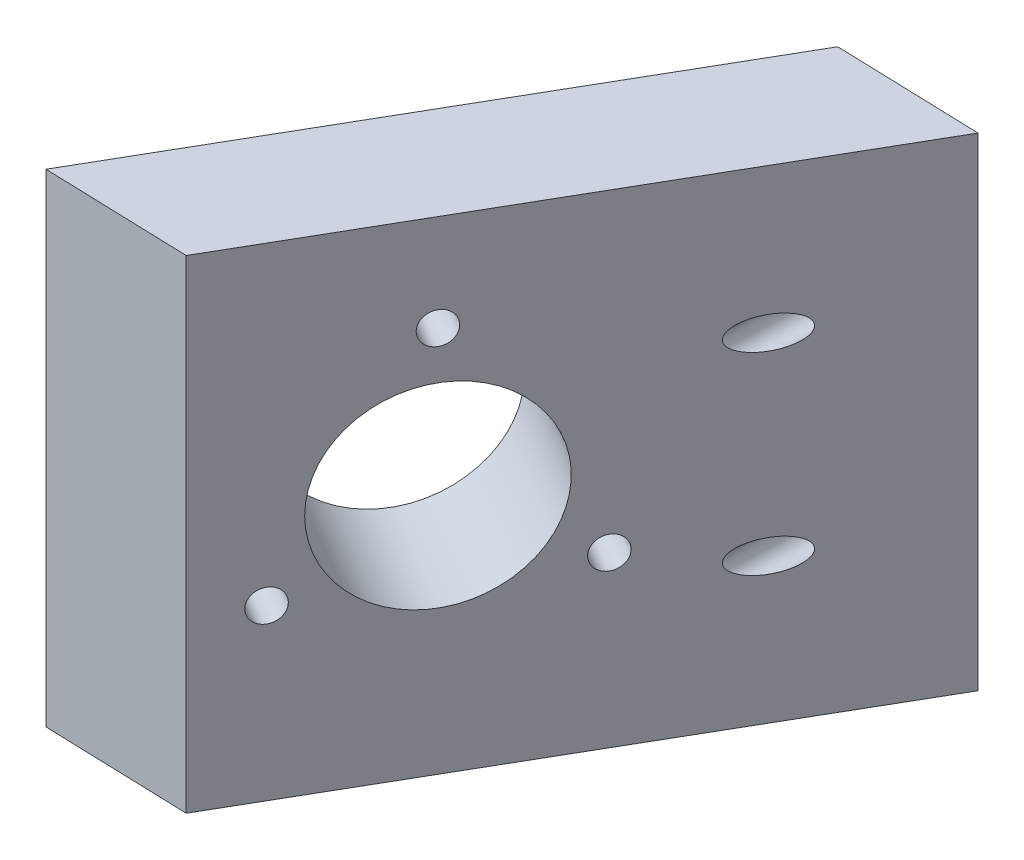
from build123d import *

# Parameters (mm, degrees)
EXTRUDE_1_DEPTH        = 50
HOLE_WIZARD_M4_1_D     = 3.3
HOLE_WIZARD_M4_1_DEPTH = 10.1
HOLE_WIZARD_M4_1_TIP   = 0.991420021
SKETCH_2_R             = 10.1
CUT_EXTRUDE_1_DEPTH    = 50
HOLE_WIZARD_M4_2_D     = 3.3


with BuildPart() as part:
    # 草图1 → 凸台-拉伸1 (new body)
    with BuildSketch(Plane(origin=(0, 0, 0), x_dir=(1, 0, 0), z_dir=(0, 1, 0))):
        Polygon((-12.088519272, -36.909676467), (17.911480728, 15.05184776), (32.903920346, 14.575660494), (2.903920346, -37.385863733), align=None)
    extrude(amount=EXTRUDE_1_DEPTH)

    # M4 螺纹孔1
    with Locations(Plane(origin=(10.045844782, 0, 25.015687746), x_dir=(-0.5, 0, 0.866025404), z_dir=(0.866025404, 0, 0.5))):
        with Locations((-17.783614548, -17.5), (-4.793233491, -40), (8.197147566, -17.5)):
            Hole(HOLE_WIZARD_M4_1_D / 2, depth=HOLE_WIZARD_M4_1_DEPTH)
            with Locations((0, 0, -(HOLE_WIZARD_M4_1_DEPTH + HOLE_WIZARD_M4_1_TIP / 2))):  # 118° drill point
                Cone(0, HOLE_WIZARD_M4_1_D / 2, HOLE_WIZARD_M4_1_TIP, mode=Mode.SUBTRACT)

    # 草图2 → 切除-拉伸1 (cut)
    with BuildSketch(Plane(origin=(-1.404680066, 0, 18.404724143), x_dir=(-0.5, 0, 0.866025404), z_dir=(-0.866025404, 0, -0.5))):
        with Locations((-4.793233491, 25)):
            Circle(SKETCH_2_R)
    extrude(amount=-CUT_EXTRUDE_1_DEPTH, mode=Mode.SUBTRACT)

    # M4 螺纹孔2 (through all)
    with Locations(Plane(origin=(0.495643511, 0, -15.60500656), x_dir=(-0.999495975, 0, -0.031745818), z_dir=(0.031745818, 0, -0.999495975))):
        with Locations((-24.92461967, 35), (-24.92461967, 15)):
            Hole(HOLE_WIZARD_M4_2_D / 2)


solid = part.part
